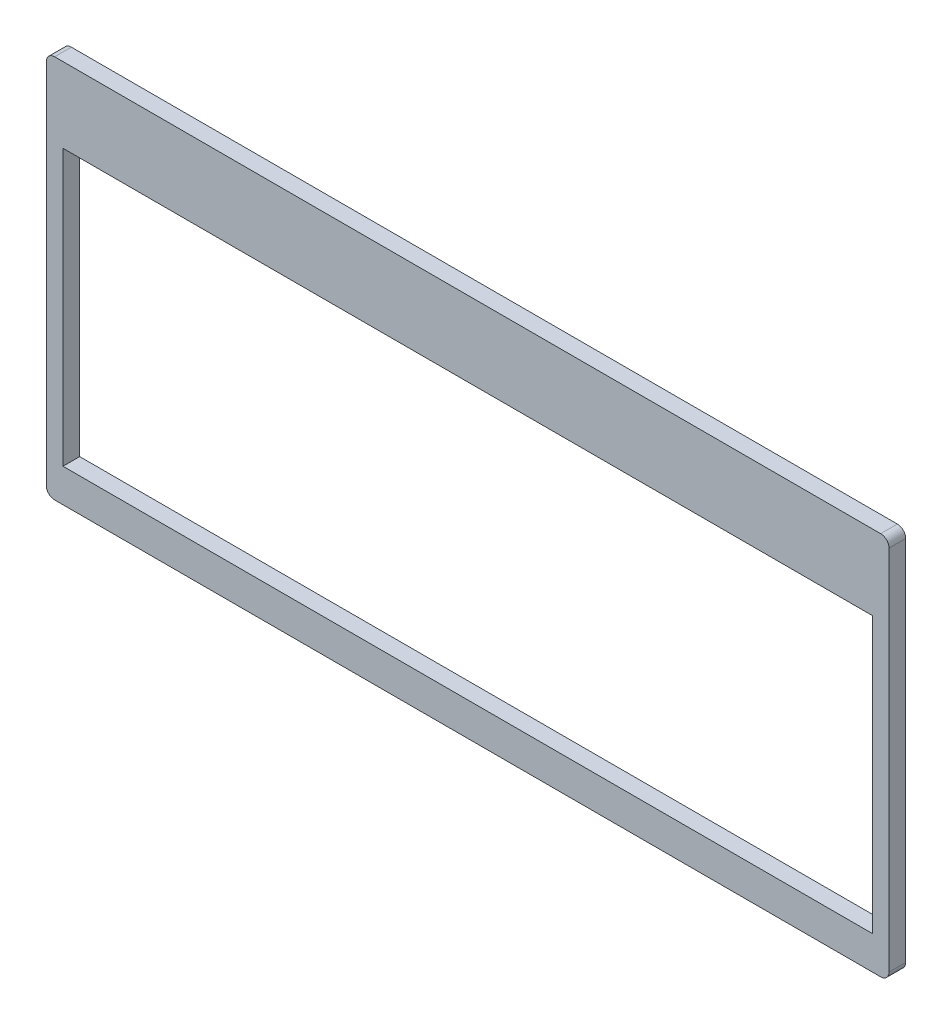
from build123d import *

# Parameters (mm, degrees)
SKETCH_1_W      = 101
SKETCH_1_H      = 46
SKETCH_1_W_2    = 97
SKETCH_1_H_2    = 33
EXTRUDE_1_DEPTH = 2
FILLET_1_R      = 1
FILLET_2_R      = 1


with BuildPart() as part:
    # 草图1 → 凸台-拉伸1 (new body)
    with BuildSketch(Plane.XY):
        Rectangle(SKETCH_1_W, SKETCH_1_H)
        with Locations((0, -2.5)):
            Rectangle(SKETCH_1_W_2, SKETCH_1_H_2, mode=Mode.SUBTRACT)
    extrude(amount=EXTRUDE_1_DEPTH)

    # 圆角1
    fillet_1_edges = [part.edges().sort_by_distance(p)[0] for p in [
        (-50.5, 23, 1),
    ]]
    fillet(fillet_1_edges, radius=FILLET_1_R)

    # 圆角2
    fillet_2_edges = [part.edges().sort_by_distance(p)[0] for p in [
        (50.5, -23, 1),
        (-50.5, -23, 1),
        (50.5, 23, 1),
    ]]
    fillet(fillet_2_edges, radius=FILLET_2_R)


solid = part.part
